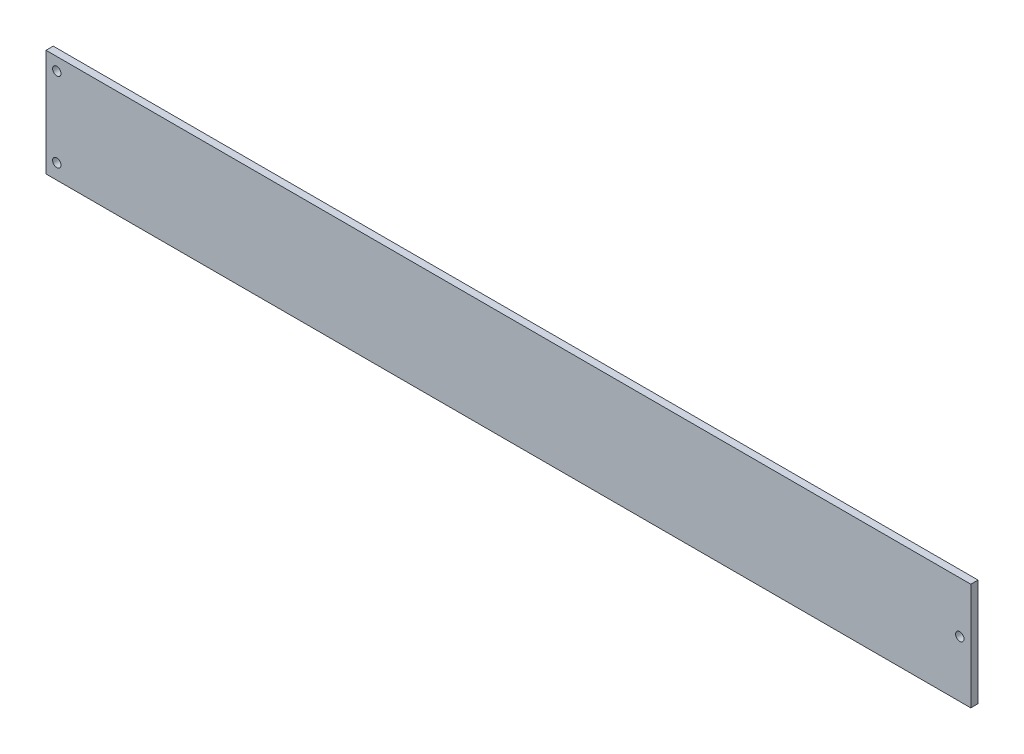
from build123d import *

# Parameters (mm, degrees)
ESQUISSE1_W             = 385
ESQUISSE1_H             = 44.6
BOSS_EXTRU_1_DEPTH      = 3
ESQUISSE3_R             = 1.75
ENL_V_MAT_EXTRU_1_DEPTH = 10


with BuildPart() as part:
    # Esquisse1 → Boss.-Extru.1 (new body)
    with BuildSketch(Plane.XY):
        Rectangle(ESQUISSE1_W, ESQUISSE1_H)
    extrude(amount=BOSS_EXTRU_1_DEPTH)

    # Esquisse3 → Enlèv. mat.-Extru.1 (cut)
    with BuildSketch(Plane.XY.offset(3)):
        with Locations((-188.00660482, 17.030275)):
            Circle(ESQUISSE3_R)
        with Locations((-188.00660482, -15.989725)):
            Circle(ESQUISSE3_R)
        with Locations((187.91339518, 1.155275)):
            Circle(ESQUISSE3_R)
    extrude(amount=-ENL_V_MAT_EXTRU_1_DEPTH, mode=Mode.SUBTRACT)


solid = part.part
